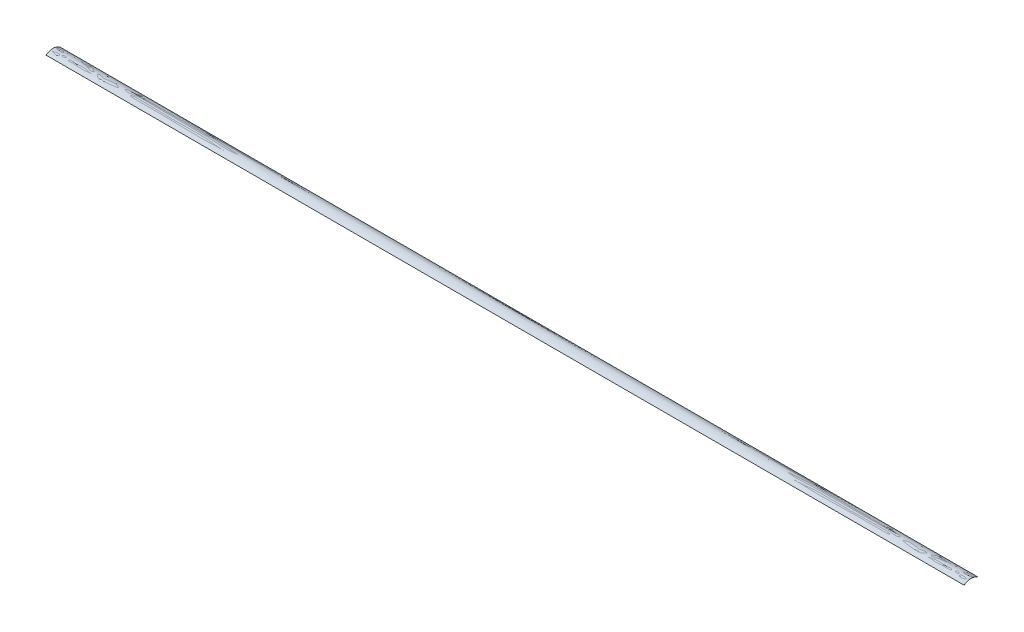
from build123d import *

# Parameters (mm, degrees)
BOSS_EXTRUDE1_DEPTH = 495.3


with BuildPart() as part:
    # Sketch1 → Boss-Extrude1 (new body, symmetric)
    with BuildSketch(Plane(origin=(0, 0, 0), x_dir=(0, 0, -1), z_dir=(1, 0, 0))):
        with BuildLine():
            Line((7.55, 0), (7.45, 0))
            add(Edge.make_bspline(
                [(-7.45, 0), (0, 4.9), (7.45, 0)],
                knots=[0, 0, 0, 1, 1, 1], degree=2))
            Line((-7.45, 0), (-7.55, 0))
            add(Edge.make_bspline(
                [(7.55, 0), (0, 5.1), (-7.55, 0)],
                knots=[0, 0, 0, 1, 1, 1], degree=2))
        make_face()
    extrude(amount=BOSS_EXTRUDE1_DEPTH, both=True)


solid = part.part
